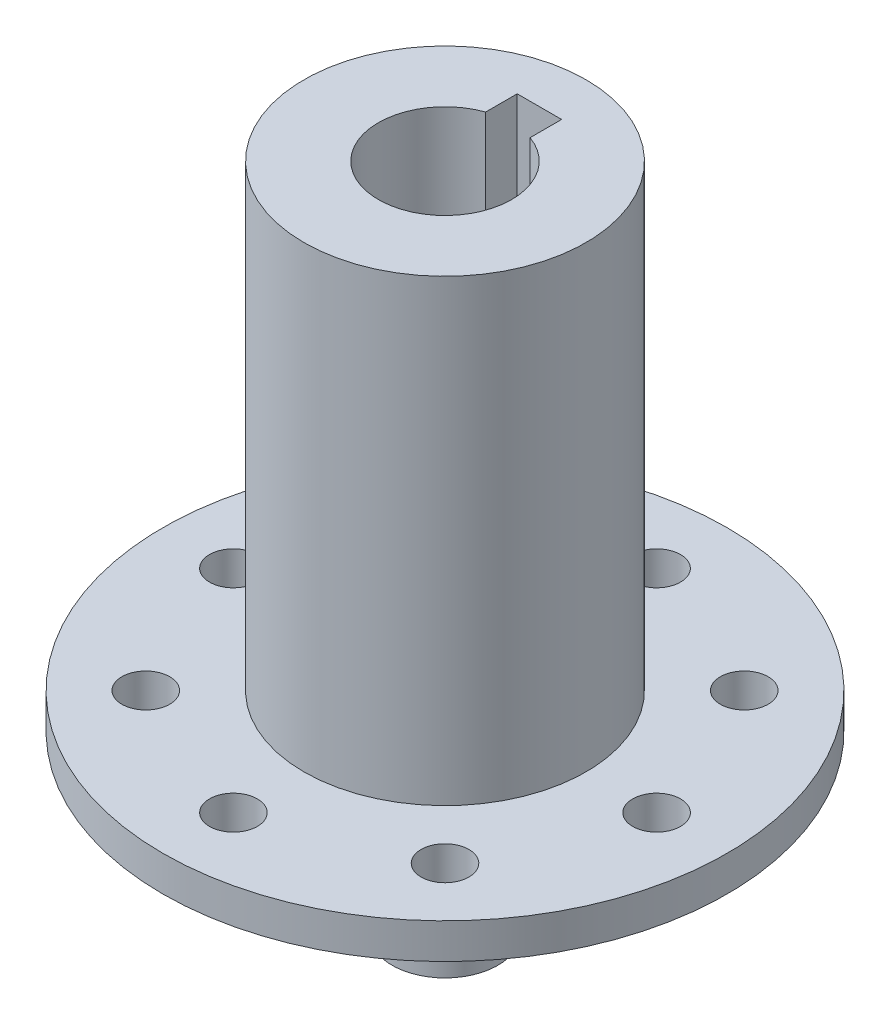
from build123d import *

# Parameters (mm, degrees)
SKETCH1_R                   = 12.7
BOSS_EXTRUDE1_DEPTH         = 41.275
SKETCH3_R                   = 25.4
BOSS_EXTRUDE3_DEPTH         = 3.175
F_8_CLEARANCE_HOLE1_D       = 4.3053
F_20_8MMTOENDOFKEYWAY_DEPTH = 22.0625
SKETCH8_R                   = 4.7625
BOSS_EXTRUDE4_DEPTH         = 15.875
FILLET1_R                   = 5


with BuildPart() as part:
    # Sketch1 → Boss-Extrude1 (new body)
    with BuildSketch(Plane(origin=(0, 0, 0), x_dir=(1, 0, 0), z_dir=(0, 1, 0))):
        Circle(SKETCH1_R)
    extrude(amount=BOSS_EXTRUDE1_DEPTH)

    # Sketch3 → Boss-Extrude3 (add)
    with BuildSketch(Plane.XZ):
        Circle(SKETCH3_R)
    extrude(amount=BOSS_EXTRUDE3_DEPTH)

    # #8 Clearance Hole1 (through all)
    with Locations(Plane(origin=(0, -3.175, 0), x_dir=(-1, 0, 0), z_dir=(0, -1, 0))):
        with Locations((0, 19.05), (-13.470384182, 13.470384182), (-19.05, 0), (-13.470384182, -13.470384182), (0, -19.05), (13.470384182, -13.470384182), (19.05, 0), (13.470384182, 13.470384182)):
            Hole(F_8_CLEARANCE_HOLE1_D / 2)

    # Sketch7 → 20.8mmToEndofKeyway (cut)
    with BuildSketch(Plane(origin=(0, 41.275, 0), x_dir=(1, 0, 0), z_dir=(0, 1, 0))):
        with BuildLine():
            Line((-2, 8.5), (2, 8.5))
            Line((2, 8.5), (2, 5.656854249))
            ThreePointArc((2, 5.656854249), (0, -6), (-2, 5.656854249))
            Line((-2, 5.656854249), (-2, 8.5))
        make_face()
    extrude(amount=-F_20_8MMTOENDOFKEYWAY_DEPTH, mode=Mode.SUBTRACT)

    # Sketch8 → Boss-Extrude4 (add)
    with BuildSketch(Plane.XZ.offset(3.175)):
        Circle(SKETCH8_R)
    extrude(amount=BOSS_EXTRUDE4_DEPTH)

    # Fillet1
    fillet1_edges = [part.edges().sort_by_distance(p)[0] for p in [
        (-4.7625, -3.175, 0),
    ]]
    fillet(fillet1_edges, radius=FILLET1_R)


solid = part.part
